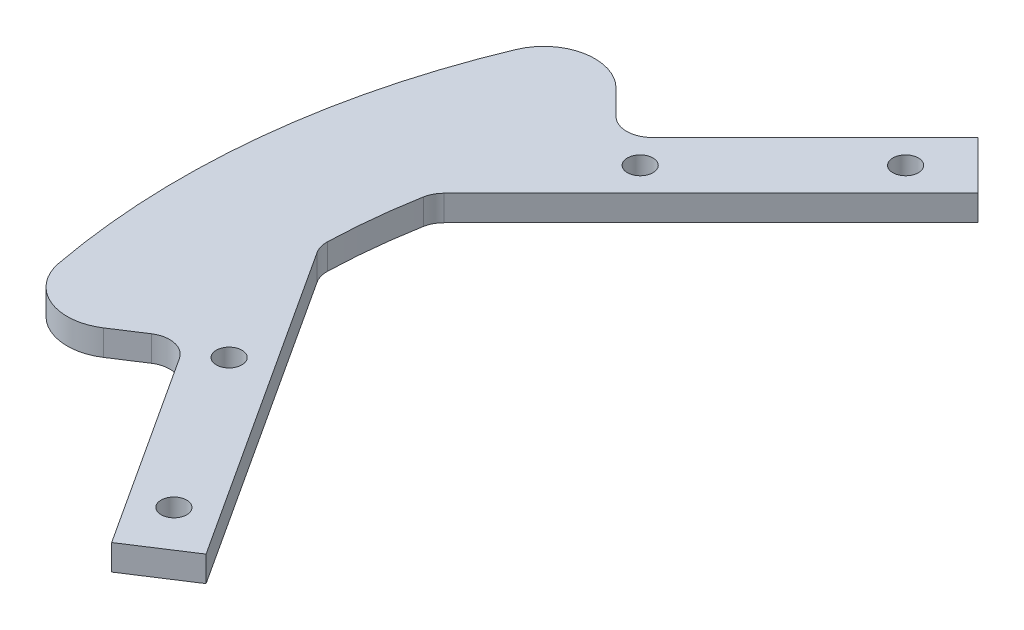
from build123d import *

# Parameters (mm, degrees)
SKETCH1_R           = 1.5
BOSS_EXTRUDE1_DEPTH = 3
FILLET1_R           = 6
FILLET2_R           = 3


with BuildPart() as part:
    # Sketch1 → Boss-Extrude1 (new body)
    with BuildSketch(Plane(origin=(0, 0, 0), x_dir=(1, 0, 0), z_dir=(0, 1, 0))):
        with BuildLine():
            Line((-74.629040009, 40.687914512), (-63.639610307, 29.69848481))
            Line((-63.639610307, 29.69848481), (-42.426406871, 50.911688245))
            Line((-42.426406871, 50.911688245), (-36.769552622, 45.254833996))
            Line((-36.769552622, 45.254833996), (-68.72500623, 13.299380388))
            ThreePointArc((-68.72500623, 13.299380388), (-69.616532676, 7.316992429), (-69.988296617, 1.279975229))
            Line((-69.988296617, 1.279975229), (-45.375058731, -36.621087439))
            Line((-45.375058731, -36.621087439), (-52.084423274, -40.978199719))
            Line((-52.084423274, -40.978199719), (-68.423594325, -15.81808268))
            Line((-68.423594325, -15.81808268), (-81.457709532, -24.282536066))
            ThreePointArc((-81.457709532, -24.282536066), (-84.534361106, 8.884919378), (-74.629040009, 40.687914512))
        make_face()
        with Locations((-43.840620434, 43.840620434)):
            Circle(SKETCH1_R, mode=Mode.SUBTRACT)
        with Locations((-59.39696962, 28.284271247)):
            Circle(SKETCH1_R, mode=Mode.SUBTRACT)
        with Locations((-51.997575213, -33.767620171)):
            Circle(SKETCH1_R, mode=Mode.SUBTRACT)
        with Locations((-63.979633983, -15.316867676)):
            Circle(SKETCH1_R, mode=Mode.SUBTRACT)
    extrude(amount=BOSS_EXTRUDE1_DEPTH)

    # Fillet1
    fillet1_edges = [part.edges().sort_by_distance(p)[0] for p in [
        (-74.629040009, 1.5, -40.687914512),
        (-81.457709532, 1.5, 24.282536066),
    ]]
    fillet(fillet1_edges, radius=FILLET1_R)

    # Fillet2
    fillet2_edges = [part.edges().sort_by_distance(p)[0] for p in [
        (-63.639610307, 1.5, -29.69848481),
        (-68.72500623, 1.5, -13.299380388),
        (-69.988296617, 1.5, -1.279975229),
        (-68.423594325, 1.5, 15.81808268),
    ]]
    fillet(fillet2_edges, radius=FILLET2_R)


solid = part.part
